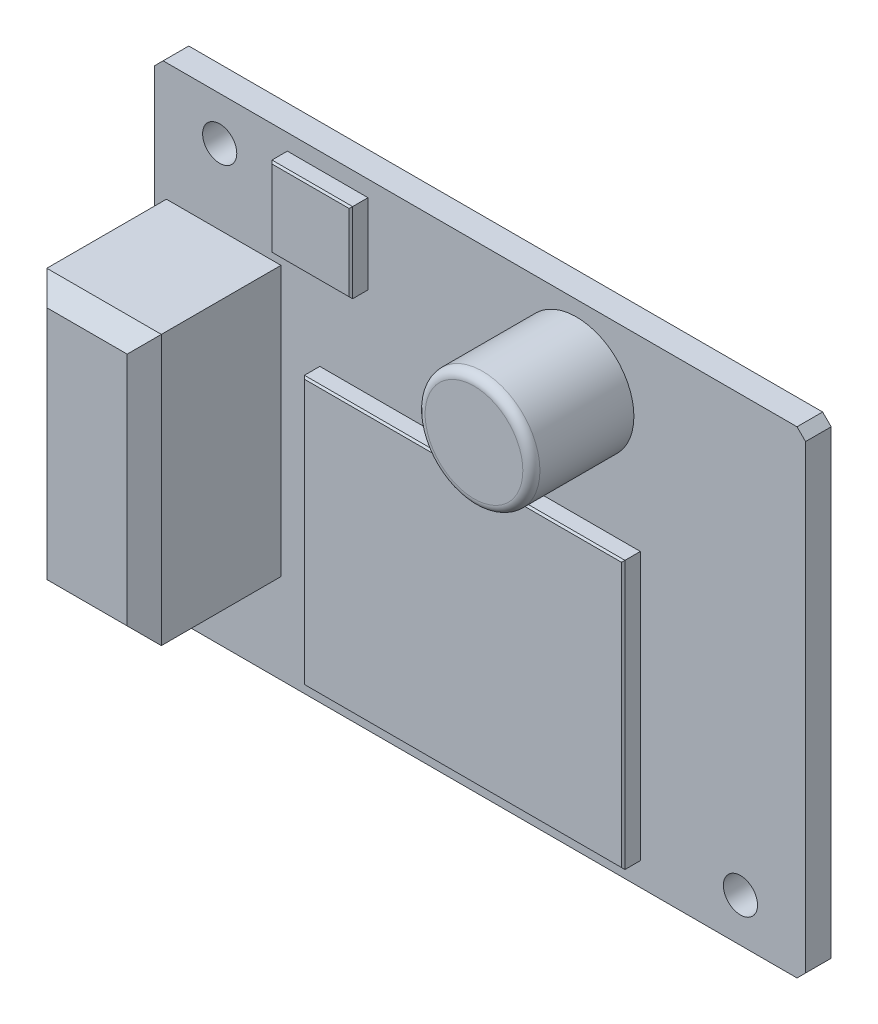
from build123d import *

# Parameters (mm, degrees)
SKETCH1_W           = 38.1
SKETCH1_H           = 27.94
SKETCH1_R           = 1
BOSS_EXTRUDE1_DEPTH = 1.5
CHAMFER1_SIZE       = 0.5
SKETCH2_W           = 18.758650548
SKETCH2_H           = 15.672811931
SKETCH2_W_2         = 4.719693546
SKETCH2_H_2         = 4.674063521
BOSS_EXTRUDE2_DEPTH = 1
SKETCH3_R           = 3.359281079
BOSS_EXTRUDE3_DEPTH = 6
CHAMFER2_SIZE       = 0.1
FILLET1_R           = 0.5
SKETCH4_W           = 6.703460486
SKETCH4_H           = 15.777656998
BOSS_EXTRUDE4_DEPTH = 8
CHAMFER3_SIZE       = 1


with BuildPart() as part:
    # Sketch1 → Boss-Extrude1 (new body)
    with BuildSketch(Plane.XY):
        Rectangle(SKETCH1_W, SKETCH1_H)
        with Locations((-15.24, 11.43)):
            Circle(SKETCH1_R, mode=Mode.SUBTRACT)
        with Locations((15.24, -11.43)):
            Circle(SKETCH1_R, mode=Mode.SUBTRACT)
    extrude(amount=BOSS_EXTRUDE1_DEPTH)

    # Chamfer1
    chamfer1_edges = [part.edges().sort_by_distance(p)[0] for p in [
        (-19.05, 13.97, 0.75),
        (19.05, 13.97, 0.75),
        (19.05, -13.97, 0.75),
        (-19.05, -13.97, 0.75),
    ]]
    chamfer(chamfer1_edges, length=CHAMFER1_SIZE)

    # Sketch2 → Boss-Extrude2 (add)
    with BuildSketch(Plane.XY.offset(1.5)):
        with Locations((0, -4.770868917)):
            Rectangle(SKETCH2_W, SKETCH2_H)
        with Locations((-8.919164238, 10.689497539)):
            Rectangle(SKETCH2_W_2, SKETCH2_H_2)
    extrude(amount=BOSS_EXTRUDE2_DEPTH)

    # Sketch3 → Boss-Extrude3 (add)
    with BuildSketch(Plane.XY.offset(1.5)):
        with Locations((5.64383642, 9.724451962)):
            Circle(SKETCH3_R)
    extrude(amount=BOSS_EXTRUDE3_DEPTH)

    # Chamfer2
    chamfer2_edges = [part.edges().sort_by_distance(p)[0] for p in [
        (-9.379325274, -4.770868917, 2.5),
        (0, -12.607274882, 2.5),
        (9.379325274, -4.770868917, 2.5),
        (0, 3.065537049, 2.5),
        (-6.559317465, 10.68949754, 2.5),
        (-8.919164238, 13.0265293, 2.5),
        (-11.279011011, 10.68949754, 2.5),
        (-8.919164238, 8.352465779, 2.5),
    ]]
    chamfer(chamfer2_edges, length=CHAMFER2_SIZE)

    # Fillet1
    fillet1_edges = [part.edges().sort_by_distance(p)[0] for p in [
        (2.284555342, 9.724451962, 7.5),
    ]]
    fillet(fillet1_edges, radius=FILLET1_R)

    # Sketch4 → Boss-Extrude4 (add)
    with BuildSketch(Plane.XY.offset(1.5)):
        with Locations((-15.005849453, -0.837932561)):
            Rectangle(SKETCH4_W, SKETCH4_H)
    extrude(amount=BOSS_EXTRUDE4_DEPTH)

    # Chamfer3
    chamfer3_edges = [part.edges().sort_by_distance(p)[0] for p in [
        (-11.65411921, -0.837932561, 9.5),
        (-15.005849453, 7.050895938, 9.5),
        (-18.357579696, -0.837932561, 9.5),
        (-15.005849453, -8.72676106, 9.5),
    ]]
    chamfer(chamfer3_edges, length=CHAMFER3_SIZE)


solid = part.part
